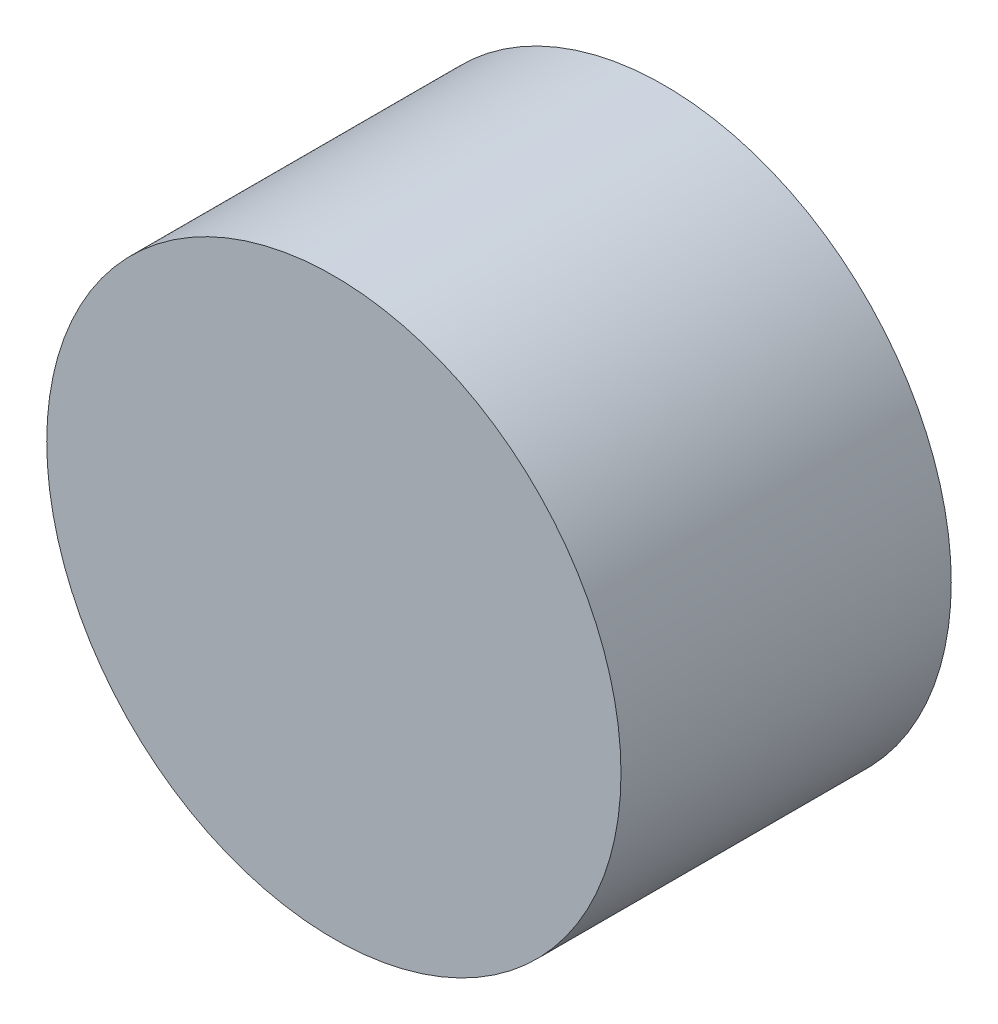
from build123d import *

# Parameters (mm, degrees)
SKETCH1_R           = 8.693605866
BOSS_EXTRUDE1_DEPTH = 10


with BuildPart() as part:
    # Sketch1 → Boss-Extrude1 (new body)
    with BuildSketch(Plane.XY):
        Circle(SKETCH1_R)
    extrude(amount=BOSS_EXTRUDE1_DEPTH)


solid = part.part
